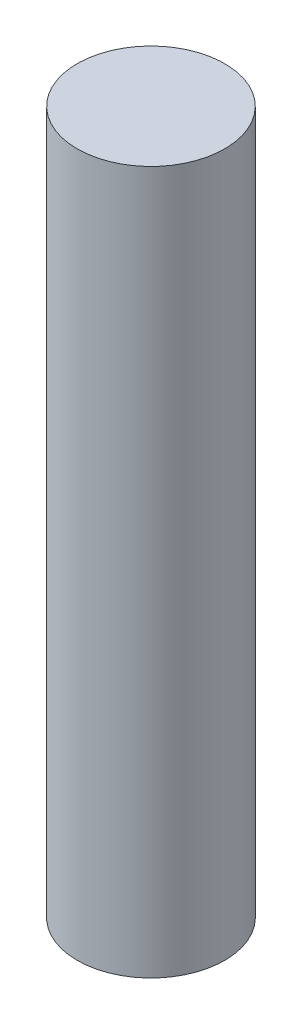
from build123d import *

# Parameters (mm, degrees)
SKETCH1_R           = 2
BOSS_EXTRUDE1_DEPTH = 19.05


with BuildPart() as part:
    # Sketch1 → Boss-Extrude1 (new body)
    with BuildSketch(Plane(origin=(0, 0, 0), x_dir=(1, 0, 0), z_dir=(0, 1, 0))):
        Circle(SKETCH1_R)
    extrude(amount=BOSS_EXTRUDE1_DEPTH)


solid = part.part
